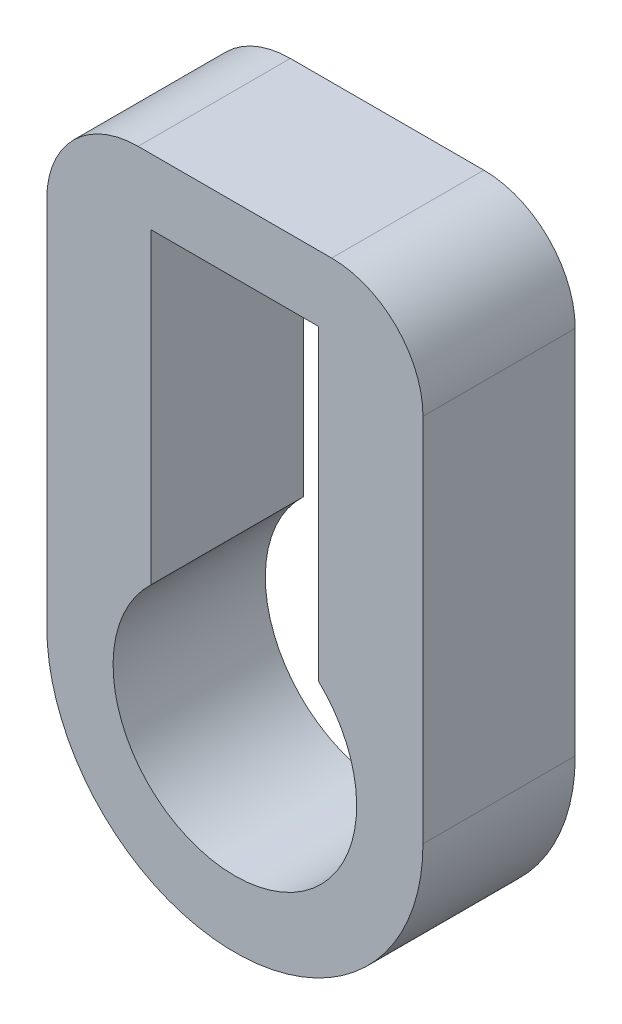
from build123d import *

# Parameters (mm, degrees)
BOSS_EXTRUDE1_DEPTH = 1.27
SKETCH2_R           = 1.016
CUT_EXTRUDE1_DEPTH  = 2.54
FILLET2_R           = 0.762


with BuildPart() as part:
    # Sketch1 → Boss-Extrude1 (new body)
    with BuildSketch(Plane.XY):
        with BuildLine():
            Line((-0.6985, 1.404959328), (-0.6985, 3.302))
            Line((-0.6985, 3.302), (0.6985, 3.302))
            Line((0.6985, 3.302), (0.6985, 1.404959328))
            ThreePointArc((0.6985, 1.404959328), (1.33374867, 0.826394245), (1.569016559, 0))
            Line((1.569016559, 0), (1.569016559, 3.850479464))
            Line((1.569016559, 3.850479464), (-1.569016559, 3.850479464))
            Line((-1.569016559, 3.850479464), (-1.569016559, 0))
            ThreePointArc((-1.569016559, 0), (-1.33374867, 0.826394245), (-0.6985, 1.404959328))
        make_face()
        with BuildLine():
            ThreePointArc((0.6985, 0), (0, -0.6985), (-0.6985, 0))
            Line((-0.6985, 0), (-1.569016559, 0))
            ThreePointArc((-1.569016559, 0), (0, -1.569016559), (1.569016559, 0))
            Line((1.569016559, 0), (0.6985, 0))
        make_face()
        with BuildLine():
            ThreePointArc((1.569016559, 0), (1.33374867, 0.826394245), (0.6985, 1.404959328))
            Line((0.6985, 1.404959328), (0.6985, 0))
            Line((0.6985, 0), (1.569016559, 0))
        make_face()
        with BuildLine():
            Line((-0.6985, 0), (-0.6985, 1.404959328))
            ThreePointArc((-0.6985, 1.404959328), (-1.33374867, 0.826394245), (-1.569016559, 0))
            Line((-1.569016559, 0), (-0.6985, 0))
        make_face()
    extrude(amount=BOSS_EXTRUDE1_DEPTH)

    # Sketch2 → Cut-Extrude1 (cut)
    with BuildSketch(Plane(origin=(0, 0, 0), x_dir=(-1, 0, 0), z_dir=(0, 0, -1))):
        Circle(SKETCH2_R)
    extrude(amount=-CUT_EXTRUDE1_DEPTH, mode=Mode.SUBTRACT)

    # Fillet2
    fillet2_edges = [part.edges().sort_by_distance(p)[0] for p in [
        (-1.569016559, 3.850479464, 0.635),
        (1.569016559, 3.850479464, 0.635),
    ]]
    fillet(fillet2_edges, radius=FILLET2_R)


solid = part.part
